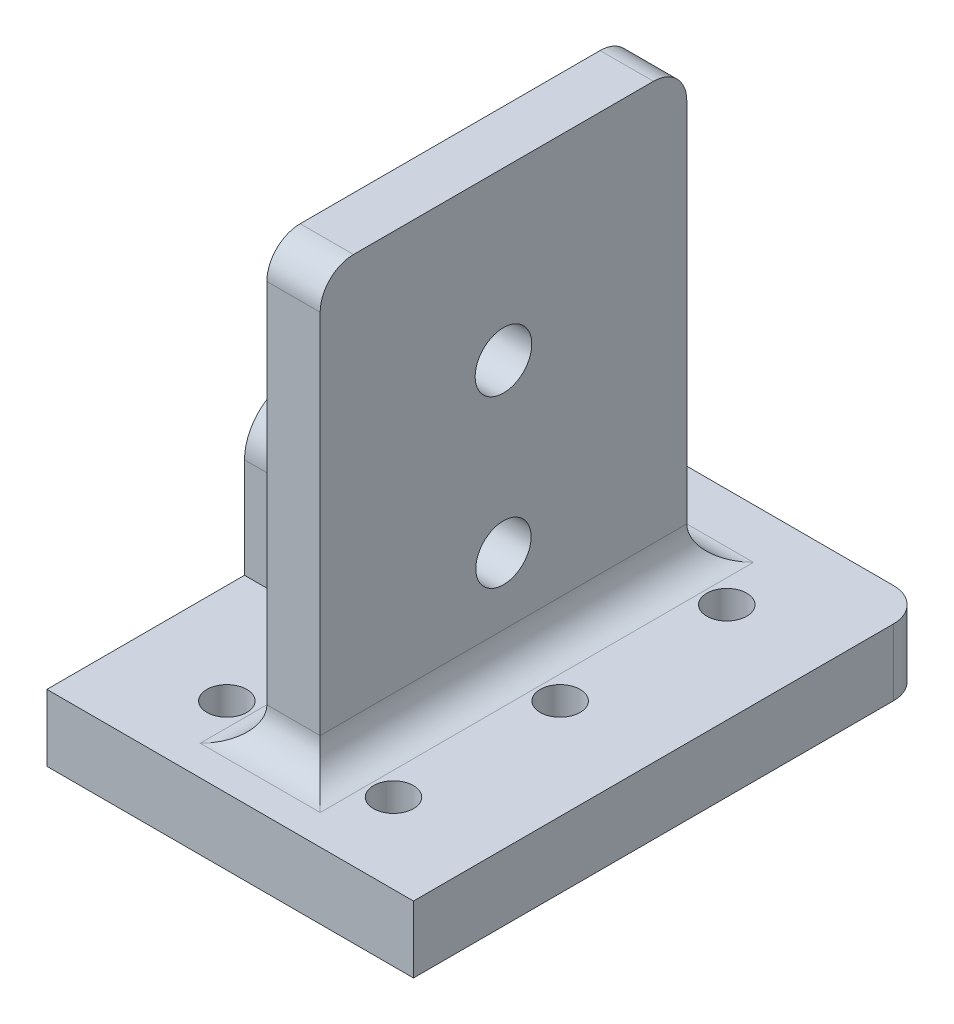
from build123d import *

# Parameters (mm, degrees)
SKETCH1_W               = 55
SKETCH1_H               = 80
BOSS_EXTRUDE1_DEPTH     = 10
SKETCH6_R               = 1.65
CUT_EXTRUDE2_DEPTH      = 55
LPATTERN1_COUNT         = 3
LPATTERN1_PITCH         = 25
MIRROR3_COPY_1_SKETCH_R = 1.65
MIRROR3_COPY_1_DEPTH    = 55
MIRROR3_COPY_2_SKETCH_R = 1.65
MIRROR3_COPY_2_DEPTH    = 55
SKETCH8_W               = 8
SKETCH8_H               = 55
BOSS_EXTRUDE3_DEPTH     = 65
FILLET3_R               = 5
SKETCH9_R               = 4.25
CUT_EXTRUDE3_DEPTH      = 32.5
CUT_EXTRUDE5_START      = -5
SKETCH11_R              = 3
CUT_EXTRUDE5_DEPTH      = 71
LPATTERN2_COUNT         = 3
LPATTERN2_PITCH         = 25
MIRROR4_START           = -5
MIRROR4_COPY_1_SKETCH_R = 3
MIRROR4_COPY_1_DEPTH    = 71
MIRROR4_COPY_2_SKETCH_R = 3
MIRROR4_COPY_2_DEPTH    = 71
CUT_EXTRUDE6_DEPTH      = 10
SKETCH13_R              = 4.15
BOSS_EXTRUDE4_DEPTH     = 23.5
SKETCH14_R              = 4.15
CUT_EXTRUDE7_DEPTH      = 20


with BuildPart() as part:
    # Sketch1 → Boss-Extrude1 (new body)
    with BuildSketch(Plane(origin=(0, 0, 0), x_dir=(1, 0, 0), z_dir=(0, 1, 0))):
        Rectangle(SKETCH1_W, SKETCH1_H)
    extrude(amount=BOSS_EXTRUDE1_DEPTH)

    # Sketch6 → Cut-Extrude2 (cut)
    with BuildSketch(Plane(origin=(0, 10, 0), x_dir=(1, 0, 0), z_dir=(0, 1, 0))):
        with Locations((-12.5, -25)):
            Circle(SKETCH6_R)
    cut_extrude2 = extrude(amount=-CUT_EXTRUDE2_DEPTH, mode=Mode.SUBTRACT)

    # LPattern1: Cut-Extrude2 ×3
    with Locations(*[(0, 0, -i * LPATTERN1_PITCH) for i in range(1, LPATTERN1_COUNT)]):
        add(cut_extrude2, mode=Mode.SUBTRACT)

    # Mirror3: Cut-Extrude2 across plane
    add(cut_extrude2.mirror(Plane(origin=(0, 0, 0), x_dir=(0, 0, 1), z_dir=(1, 0, 0))), mode=Mode.SUBTRACT)

    # Mirror3 copy 1 sketch → Mirror3 copy 1 (cut)
    with BuildSketch(Plane(origin=(0, 10, -25), x_dir=(-1, 0, 0), z_dir=(0, 1, 0))):
        with Locations((-12.5, 25)):
            Circle(MIRROR3_COPY_1_SKETCH_R)
    extrude(amount=-MIRROR3_COPY_1_DEPTH, mode=Mode.SUBTRACT)

    # Mirror3 copy 2 sketch → Mirror3 copy 2 (cut)
    with BuildSketch(Plane(origin=(0, 10, -50), x_dir=(-1, 0, 0), z_dir=(0, 1, 0))):
        with Locations((-12.5, 25)):
            Circle(MIRROR3_COPY_2_SKETCH_R)
    extrude(amount=-MIRROR3_COPY_2_DEPTH, mode=Mode.SUBTRACT)

    # Sketch8 → Boss-Extrude3 (add)
    with BuildSketch(Plane(origin=(0, 10, 0), x_dir=(1, 0, 0), z_dir=(0, 1, 0))):
        Rectangle(SKETCH8_W, SKETCH8_H)
    extrude(amount=BOSS_EXTRUDE3_DEPTH)

    # Fillet3
    fillet3_edges = [part.edges().sort_by_distance(p)[0] for p in [
        (4, 10, 0),
        (0, 10, -27.5),
        (-4, 10, 0),
        (0, 10, 27.5),
        (0, 75, -27.5),
        (0, 75, 27.5),
        (-27.5, 5, -40),
        (27.5, 5, -40),
    ]]
    fillet(fillet3_edges, radius=FILLET3_R)

    # Sketch9 → Cut-Extrude3 (cut, through all)
    with BuildSketch(Plane.ZY.offset(4)):
        with Locations((0, 50)):
            Circle(SKETCH9_R)
    extrude(amount=-CUT_EXTRUDE3_DEPTH, mode=Mode.SUBTRACT)

    # Sketch11 → Cut-Extrude5 (cut)
    with BuildSketch(Plane(origin=(0, 10, 0), x_dir=(1, 0, 0), z_dir=(0, 1, 0)).offset(CUT_EXTRUDE5_START)):
        with Locations((-12.5, -25)):
            Circle(SKETCH11_R)
    cut_extrude5 = extrude(amount=CUT_EXTRUDE5_DEPTH, mode=Mode.SUBTRACT)

    # LPattern2: Cut-Extrude5 ×3
    with Locations(*[(0, 0, -i * LPATTERN2_PITCH) for i in range(1, LPATTERN2_COUNT)]):
        add(cut_extrude5, mode=Mode.SUBTRACT)

    # Mirror4: Cut-Extrude5 across plane
    add(cut_extrude5.mirror(Plane(origin=(0, 0, 0), x_dir=(0, 0, 1), z_dir=(1, 0, 0))), mode=Mode.SUBTRACT)

    # Mirror4 copy 1 sketch → Mirror4 copy 1 (cut)
    with BuildSketch(Plane(origin=(0, 10, -25), x_dir=(-1, 0, 0), z_dir=(0, 1, 0)).offset(MIRROR4_START)):
        with Locations((-12.5, 25)):
            Circle(MIRROR4_COPY_1_SKETCH_R)
    extrude(amount=MIRROR4_COPY_1_DEPTH, mode=Mode.SUBTRACT)

    # Mirror4 copy 2 sketch → Mirror4 copy 2 (cut)
    with BuildSketch(Plane(origin=(0, 10, -50), x_dir=(-1, 0, 0), z_dir=(0, 1, 0)).offset(MIRROR4_START)):
        with Locations((-12.5, 25)):
            Circle(MIRROR4_COPY_2_SKETCH_R)
    extrude(amount=MIRROR4_COPY_2_DEPTH, mode=Mode.SUBTRACT)

    # Sketch12 → Cut-Extrude6 (cut)
    with BuildSketch(Plane(origin=(0, 10, 0), x_dir=(1, 0, 0), z_dir=(0, 1, 0))):
        Polygon((12.5, -37), (-38.055736231, -37), (-38.055736231, -44.287300659), (40.369344369, -44.287300659), (40.369344369, -37), align=None)
    extrude(amount=-CUT_EXTRUDE6_DEPTH, mode=Mode.SUBTRACT)

    # Sketch13 → Boss-Extrude4 (add)
    with BuildSketch(Plane.ZY.offset(4)):
        with BuildLine():
            Line((-7.35, 25), (-7.35, 0))
            Line((-7.35, 0), (7.35, 0))
            Line((7.35, 0), (7.35, 25))
            ThreePointArc((7.35, 25), (0, 32.35), (-7.35, 25))
        make_face()
        with Locations((0, 25)):
            Circle(SKETCH13_R, mode=Mode.SUBTRACT)
    extrude(amount=BOSS_EXTRUDE4_DEPTH)

    # Sketch14 → Cut-Extrude7 (cut)
    with BuildSketch(Plane.ZY.offset(4)):
        with Locations((0, 25)):
            Circle(SKETCH14_R)
    extrude(amount=-CUT_EXTRUDE7_DEPTH, mode=Mode.SUBTRACT)


solid = part.part
